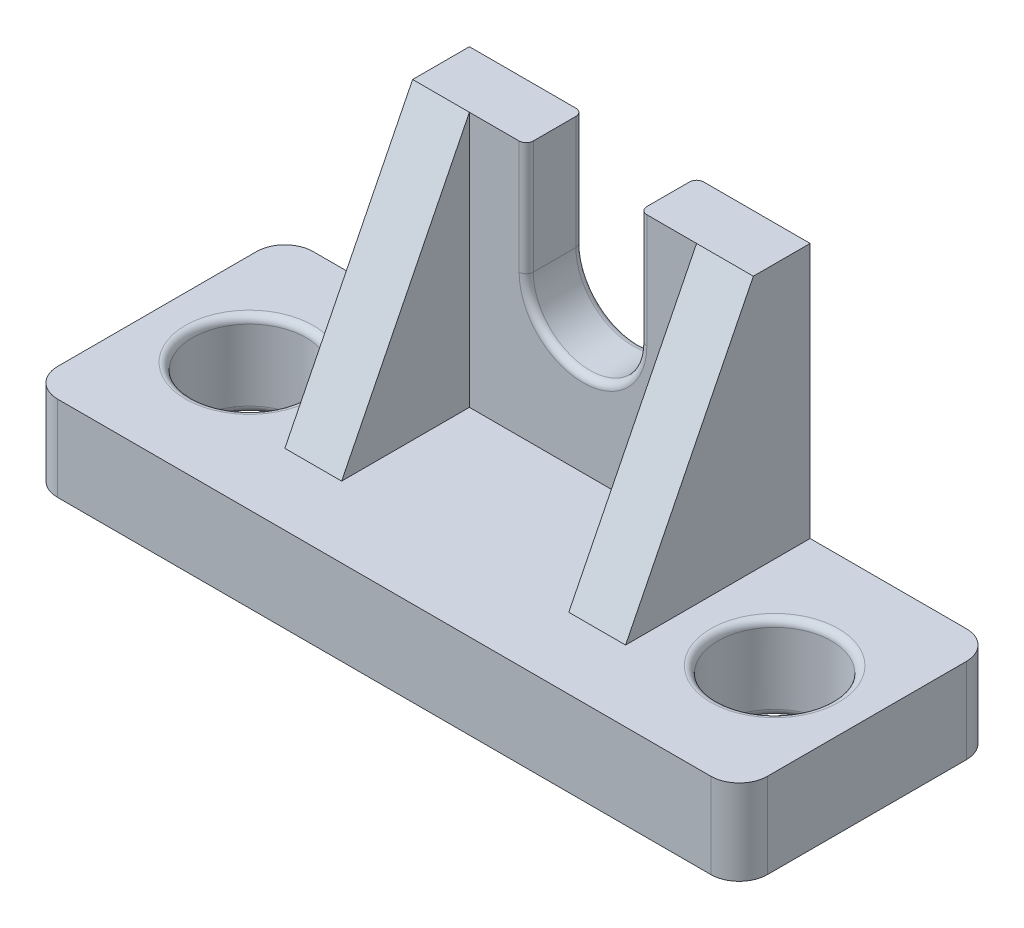
from build123d import *

# Parameters (mm, degrees)
SKETCH1_W           = 100
SKETCH1_H           = 12
BOSS_EXTRUDE1_DEPTH = 36
SKETCH2_W           = 48
SKETCH2_H           = 26
BOSS_EXTRUDE2_DEPTH = 36
SKETCH3_W           = 32
SKETCH3_H           = 18
CUT_EXTRUDE1_DEPTH  = 36
CUT_EXTRUDE2_START  = -48
CUT_EXTRUDE2_DEPTH  = 48
CUT_EXTRUDE5_DEPTH  = 36
SKETCH6_R           = 8
CUT_EXTRUDE6_DEPTH  = 36
FILLET1_R           = 4
FILLET2_R           = 1


with BuildPart() as part:
    # Sketch1 → Boss-Extrude1 (new body)
    with BuildSketch(Plane.XY):
        with Locations((50, 6)):
            Rectangle(SKETCH1_W, SKETCH1_H)
    extrude(amount=-BOSS_EXTRUDE1_DEPTH)

    # Sketch2 → Boss-Extrude2 (add)
    with BuildSketch(Plane(origin=(0, 12, 0), x_dir=(1, 0, 0), z_dir=(0, 1, 0))):
        with Locations((50, 23)):
            Rectangle(SKETCH2_W, SKETCH2_H)
    extrude(amount=BOSS_EXTRUDE2_DEPTH)

    # Sketch3 → Cut-Extrude1 (cut)
    with BuildSketch(Plane(origin=(0, 48, 0), x_dir=(1, 0, 0), z_dir=(0, 1, 0))):
        with Locations((50, 19)):
            Rectangle(SKETCH3_W, SKETCH3_H)
    extrude(amount=-CUT_EXTRUDE1_DEPTH, mode=Mode.SUBTRACT)

    # Sketch4 → Cut-Extrude2 (cut)
    with BuildSketch(Plane.ZY.offset(-26).offset(CUT_EXTRUDE2_START)):
        Polygon((-28, 48), (-10, 12), (-10, 48), align=None)
    extrude(amount=CUT_EXTRUDE2_DEPTH, mode=Mode.SUBTRACT)

    # Sketch5 → Cut-Extrude5 (cut)
    with BuildSketch(Plane.XY.offset(-28)):
        with BuildLine():
            Line((42, 48), (58, 48))
            Line((58, 48), (58, 32))
            ThreePointArc((58, 32), (50, 24), (42, 32))
            Line((42, 32), (42, 48))
        make_face()
    extrude(amount=-CUT_EXTRUDE5_DEPTH, mode=Mode.SUBTRACT)

    # Sketch6 → Cut-Extrude6 (cut)
    with BuildSketch(Plane(origin=(0, 12, 0), x_dir=(1, 0, 0), z_dir=(0, 1, 0))):
        with Locations((13, 18)):
            Circle(SKETCH6_R)
        with Locations((87, 18)):
            Circle(SKETCH6_R)
    extrude(amount=-CUT_EXTRUDE6_DEPTH, mode=Mode.SUBTRACT)

    # Fillet1
    fillet1_edges = [part.edges().sort_by_distance(p)[0] for p in [
        (100, 6, -36),
        (0, 6, -36),
        (100, 6, 0),
        (0, 6, 0),
    ]]
    fillet(fillet1_edges, radius=FILLET1_R)

    # Fillet2
    fillet2_edges = [part.edges().sort_by_distance(p)[0] for p in [
        (50, 24, -36),
        (42, 40, -36),
        (58, 40, -36),
        (50, 24, -28),
        (58, 40, -28),
        (42, 40, -28),
        (79, 0, -18),
        (79, 12, -18),
        (5, 0, -18),
        (5, 12, -18),
    ]]
    fillet(fillet2_edges, radius=FILLET2_R)


solid = part.part
